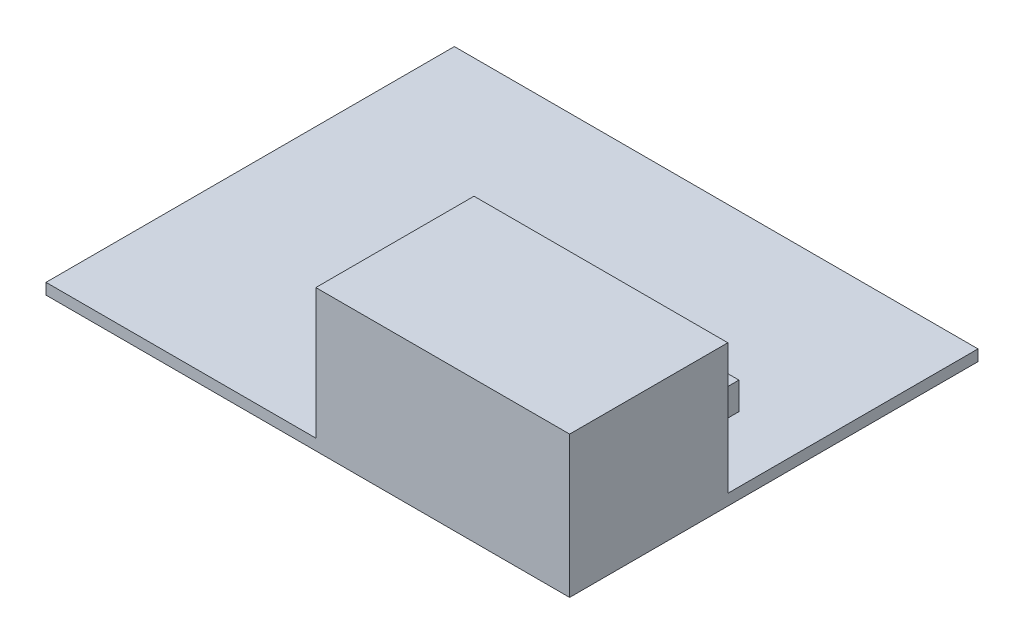
from build123d import *

# Parameters (mm, degrees)
SKETCH1_W           = 76.5048
SKETCH1_H           = 59.6646
BOSS_EXTRUDE1_DEPTH = 1.62
SKETCH2_W           = 37.084
SKETCH2_H           = 23.114
BOSS_EXTRUDE2_DEPTH = 19.05
SKETCH3_W           = 6.362801742
SKETCH3_H           = 5.001103528
BOSS_EXTRUDE3_DEPTH = 4


with BuildPart() as part:
    # Sketch1 → Boss-Extrude1 (new body)
    with BuildSketch(Plane(origin=(0, 0, 0), x_dir=(1, 0, 0), z_dir=(0, 1, 0))):
        Rectangle(SKETCH1_W, SKETCH1_H)
    extrude(amount=BOSS_EXTRUDE1_DEPTH)

    # Sketch2 → Boss-Extrude2 (add)
    with BuildSketch(Plane(origin=(0, 1.62, 0), x_dir=(1, 0, 0), z_dir=(0, 1, 0))):
        with Locations((19.7104, -18.2753)):
            Rectangle(SKETCH2_W, SKETCH2_H)
    extrude(amount=BOSS_EXTRUDE2_DEPTH)

    # Sketch3 → Boss-Extrude3 (add)
    with BuildSketch(Plane(origin=(0, 1.62, 0), x_dir=(1, 0, 0), z_dir=(0, 1, 0))):
        with Locations((25.5524, 1.9177)):
            Rectangle(SKETCH3_W, SKETCH3_H)
    extrude(amount=BOSS_EXTRUDE3_DEPTH)


solid = part.part
